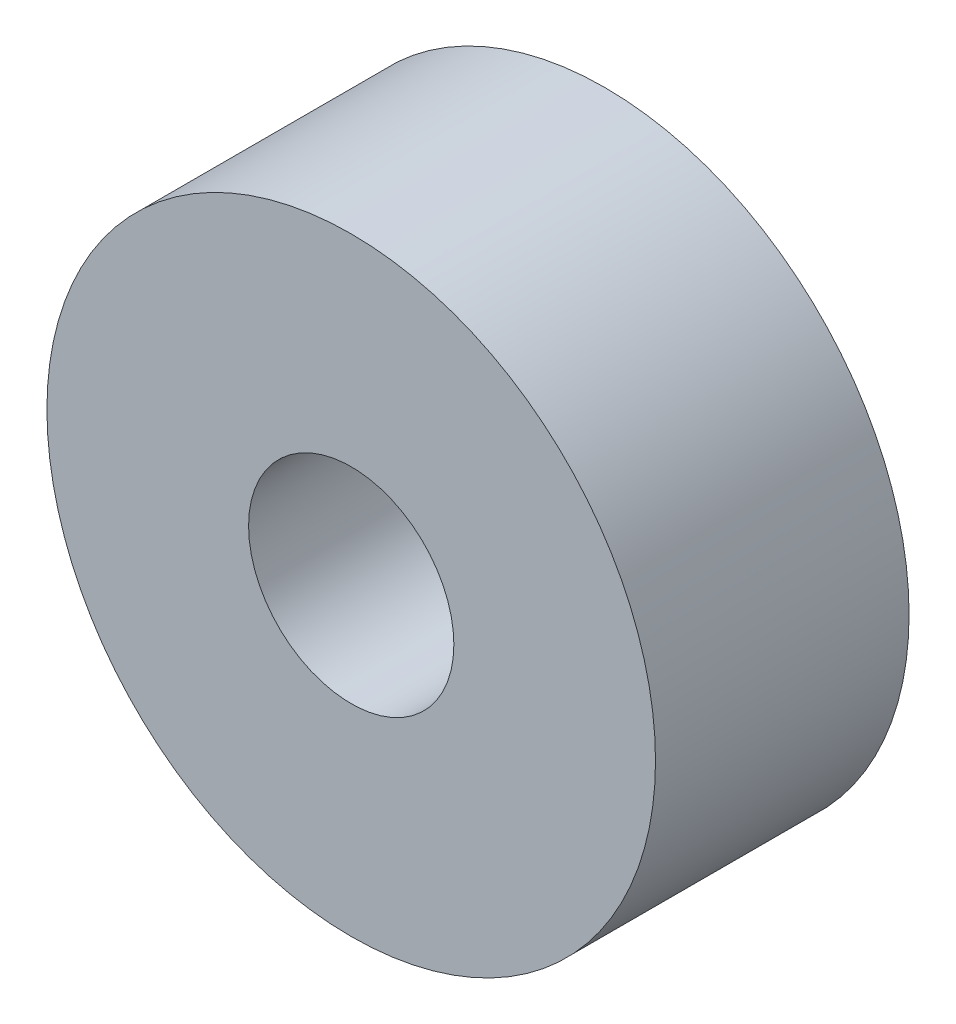
from build123d import *

# Parameters (mm, degrees)
SKETCH1_R           = 4.7625
SKETCH1_R_2         = 1.60655
BOSS_EXTRUDE1_DEPTH = 3.96875


with BuildPart() as part:
    # Sketch1 → Boss-Extrude1 (new body)
    with BuildSketch(Plane.XY):
        Circle(SKETCH1_R)
        Circle(SKETCH1_R_2, mode=Mode.SUBTRACT)
    extrude(amount=BOSS_EXTRUDE1_DEPTH)


solid = part.part
